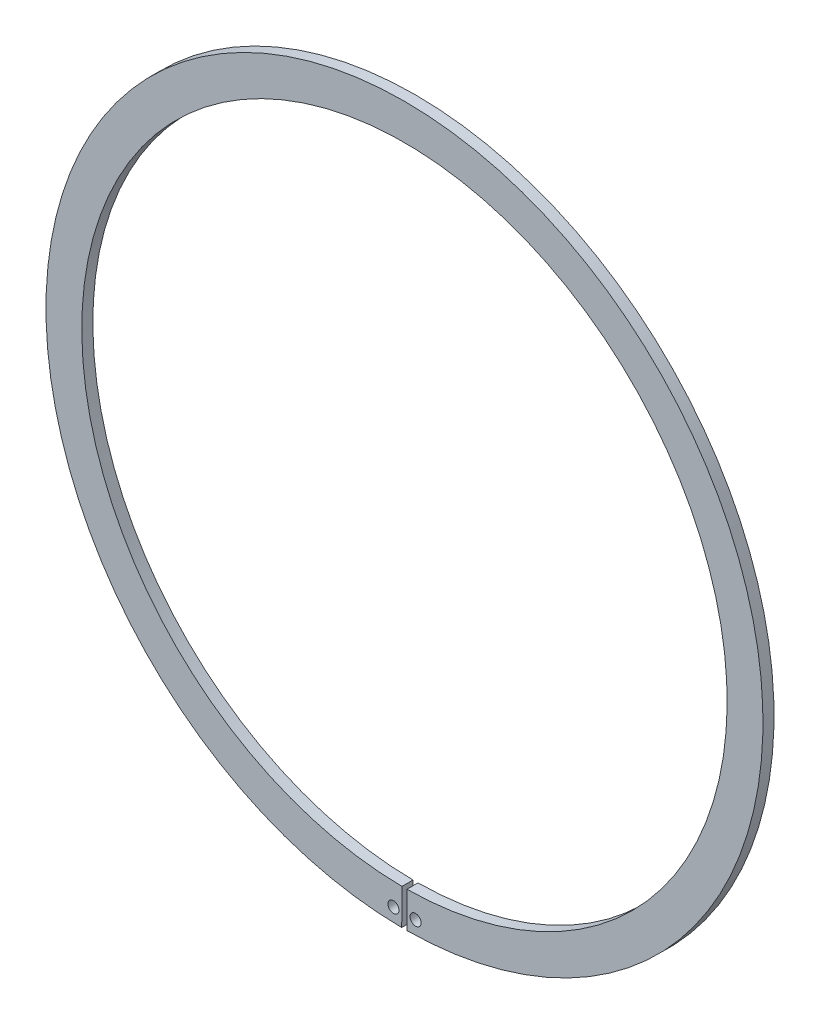
from build123d import *

# Parameters (mm, degrees)
BODYSKE_R   = 2.5
BODY_DEPTH  = 5
UNLUG_DEPTH = 5


with BuildPart() as part:
    # BodySke → Body (new body)
    with BuildSketch(Plane.XY):
        with BuildLine():
            Line((1.125154131, -145.995664416), (1.25, -162.195183344))
            ThreePointArc((1.25, -162.195183344), (5.676371918, -162.100644051), (10.098514589, -161.885329796))
            ThreePointArc((10.098514589, -161.885329796), (10.563651318, -161.684989651), (10.7954035, -161.23467945))
            Line((10.7954035, -161.23467945), (10.957598268, -160.002687876))
            ThreePointArc((10.957598268, -160.002687876), (13.335118636, -155.229150535), (18.145600866, -152.92729855))
            ThreePointArc((18.145600866, -152.92729855), (0, 162), (-18.145600866, -152.92729855))
            ThreePointArc((-18.145600866, -152.92729855), (-13.335118636, -155.229150535), (-10.957598268, -160.002687876))
            Line((-10.957598268, -160.002687876), (-10.7954035, -161.23467945))
            ThreePointArc((-10.7954035, -161.23467945), (-10.563651318, -161.684989651), (-10.098514589, -161.885329796))
            ThreePointArc((-10.098514589, -161.885329796), (-5.676371918, -162.100644051), (-1.25, -162.195183344))
            Line((-1.25, -162.195183344), (-1.125154131, -145.995664416))
            ThreePointArc((-1.125154131, -145.995664416), (0, 146), (1.125154131, -145.995664416))
        make_face()
        with Locations((5, -156.019902577)):
            Circle(BODYSKE_R, mode=Mode.SUBTRACT)
        with Locations((-5, -156.019902577)):
            Circle(BODYSKE_R, mode=Mode.SUBTRACT)
    extrude(amount=-BODY_DEPTH)

    # UnlSke → Unlug (add, through all)
    with BuildSketch(Plane.XY):
        with BuildLine():
            Line((-7.791082109, -162.01277431), (-7.012934574, -145.831473793))
            ThreePointArc((-7.012934574, -145.831473793), (0, 146), (7.012934574, -145.831473793))
            Line((7.012934574, -145.831473793), (7.791082109, -162.01277431))
            ThreePointArc((7.791082109, -162.01277431), (0, 162.2), (-7.791082109, -162.01277431))
        make_face()
    extrude(amount=-UNLUG_DEPTH)


solid = part.part
